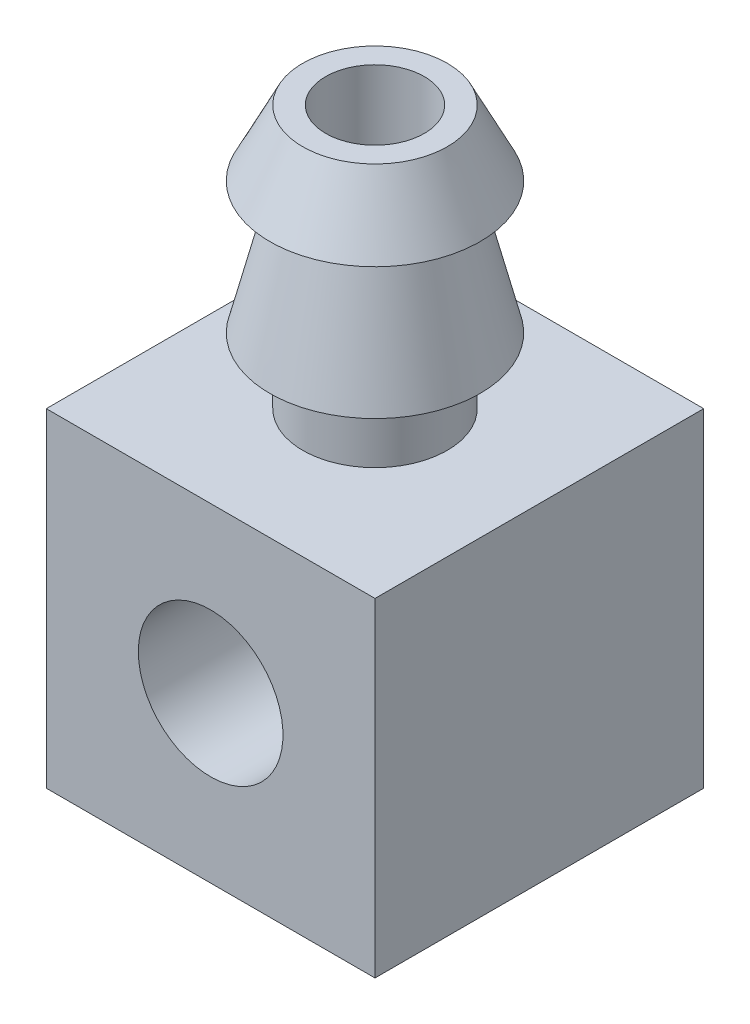
from build123d import *

# Parameters (mm, degrees)
SKETCH1_W           = 5
SKETCH1_H           = 5
BOSS_EXTRUDE1_DEPTH = 5
SKETCH5_R           = 0.75
CUT_EXTRUDE1_DEPTH  = 8
SKETCH6_R           = 1.1
CUT_EXTRUDE2_DEPTH  = 8


with BuildPart() as part:
    # Sketch1 → Boss-Extrude1 (new body)
    with BuildSketch(Plane.XY):
        Rectangle(SKETCH1_W, SKETCH1_H)
    extrude(amount=BOSS_EXTRUDE1_DEPTH)

    # Sketch2 → Revolve1 (revolve)
    with BuildSketch(Plane(origin=(0, 0, 0), x_dir=(0, 0, -1), z_dir=(1, 0, 0))):
        Polygon((-2.5, 2.5), (-2.5, 6.5), (-3.6, 6.5), (-4.1, 5.5), (-3.6, 5.5), (-4.1, 3.5), (-3.6, 3.5), (-3.6, 2.5), align=None)
    revolve(axis=Axis((0, 2.5, 2.5), (0, 1, 0)))

    # Sketch5 → Cut-Extrude1 (cut)
    with BuildSketch(Plane(origin=(0, 6.5, 0), x_dir=(1, 0, 0), z_dir=(0, 1, 0))):
        with Locations((0, -2.5)):
            Circle(SKETCH5_R)
    extrude(amount=-CUT_EXTRUDE1_DEPTH, mode=Mode.SUBTRACT)

    # Sketch6 → Cut-Extrude2 (cut)
    with BuildSketch(Plane(origin=(0, 0, 0), x_dir=(-1, 0, 0), z_dir=(0, 0, -1))):
        Circle(SKETCH6_R)
    extrude(amount=-CUT_EXTRUDE2_DEPTH, mode=Mode.SUBTRACT)


solid = part.part
